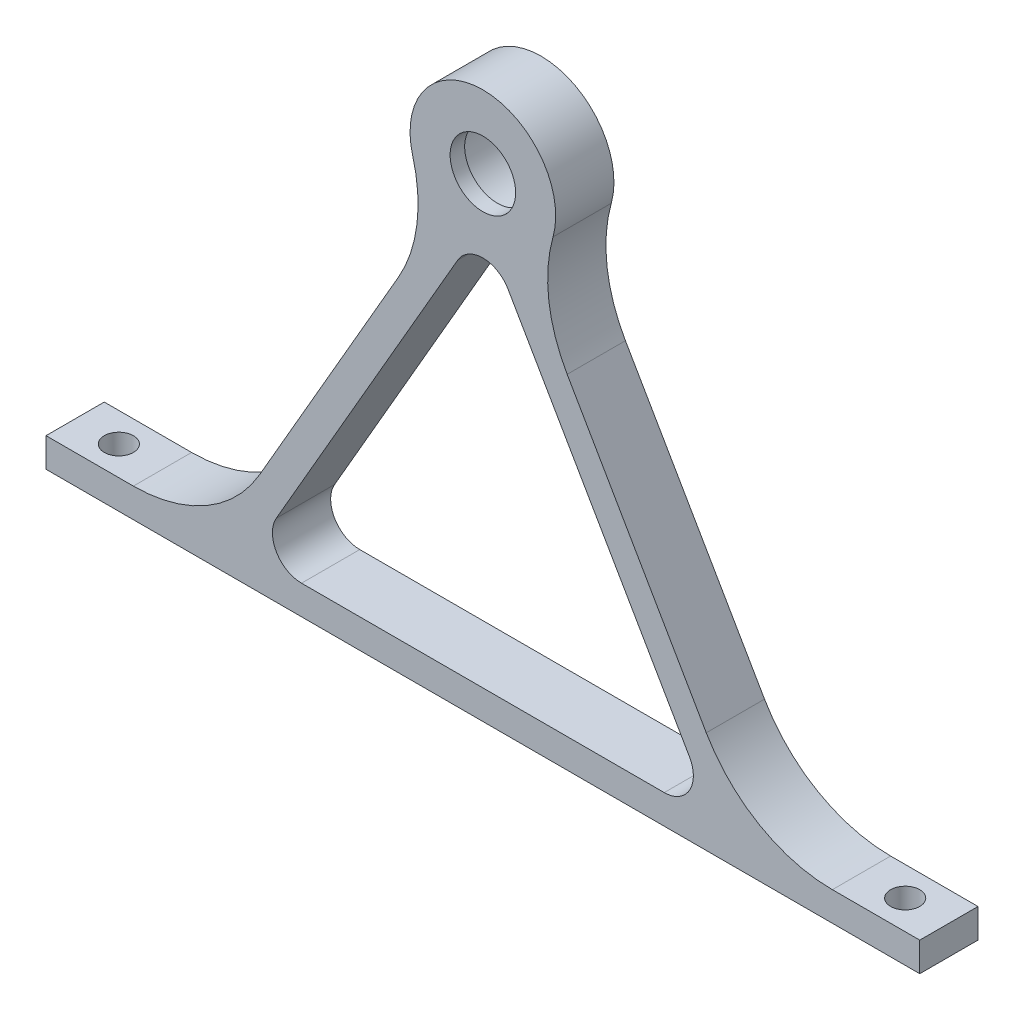
from build123d import *

# Parameters (mm, degrees)
ESQUISSE1_R                  = 3
BOSS_EXTRU_2_DEPTH           = 4
ESQUISSE2_R                  = 5
ESQUISSE2_R_2                = 2.25
BOSS_EXTRU_3_DEPTH           = 1
ESQUISSE3_R                  = 1
ENL_V_MAT_EXTRU_2_DEPTH      = 36.569219382
ENL_V_MAT_EXTRU_2_DEPTH_BACK = 3


with BuildPart() as part:
    # Esquisse1 → Boss.-Extru.2 (new body)
    with BuildSketch(Plane.XY):
        with BuildLine():
            Line((-30, 0), (30, 0))
            Line((30, 0), (30, 2))
            Line((30, 2), (24, 2))
            ThreePointArc((24, 2), (19, 3.339745962), (15.339745962, 7))
            Line((15.339745962, 7), (5.789084023, 23.542231724))
            ThreePointArc((5.789084023, 23.542231724), (4.528486677, 27.286561462), (4.81644602, 31.226890162))
            ThreePointArc((4.81644602, 31.226890162), (0, 37.569219382), (-4.81644602, 31.226890162))
            ThreePointArc((-4.81644602, 31.226890162), (-4.528486677, 27.286561462), (-5.789084023, 23.542231724))
            Line((-5.789084023, 23.542231724), (-15.339745962, 7))
            ThreePointArc((-15.339745962, 7), (-19, 3.339745962), (-24, 2))
            Line((-24, 2), (-30, 2))
            Line((-30, 2), (-30, 0))
        make_face()
        with Locations((0, 32.569219382)):
            Circle(ESQUISSE1_R, mode=Mode.SUBTRACT)
        with BuildLine():
            Line((-12.452994616, 2), (12.452994616, 2))
            ThreePointArc((12.452994616, 2), (14.185045424, 3), (14.185045424, 5))
            Line((14.185045424, 5), (1.732050808, 26.569219382))
            ThreePointArc((1.732050808, 26.569219382), (0, 27.569219382), (-1.732050808, 26.569219382))
            Line((-1.732050808, 26.569219382), (-14.185045424, 5))
            ThreePointArc((-14.185045424, 5), (-14.185045424, 3), (-12.452994616, 2))
        make_face(mode=Mode.SUBTRACT)
    extrude(amount=BOSS_EXTRU_2_DEPTH)

    # Esquisse2 → Boss.-Extru.3 (add)
    with BuildSketch(Plane.XY.offset(4)):
        with Locations((0, 32.569219382)):
            Circle(ESQUISSE2_R)
        with Locations((0, 32.569219382)):
            Circle(ESQUISSE2_R_2, mode=Mode.SUBTRACT)
    extrude(amount=-BOSS_EXTRU_3_DEPTH)

    # Esquisse3 → Enlèv. mat.-Extru.2 (cut, two sides)
    with BuildSketch(Plane(origin=(0, 2, 0), x_dir=(1, 0, 0), z_dir=(0, 1, 0))) as enl_v_mat_extru_2_sk:
        with Locations((27, -2)):
            Circle(ESQUISSE3_R)
        with Locations((-27, -2)):
            Circle(ESQUISSE3_R)
    extrude(amount=ENL_V_MAT_EXTRU_2_DEPTH, mode=Mode.SUBTRACT)
    extrude(enl_v_mat_extru_2_sk.sketch, amount=-ENL_V_MAT_EXTRU_2_DEPTH_BACK, mode=Mode.SUBTRACT)


solid = part.part
